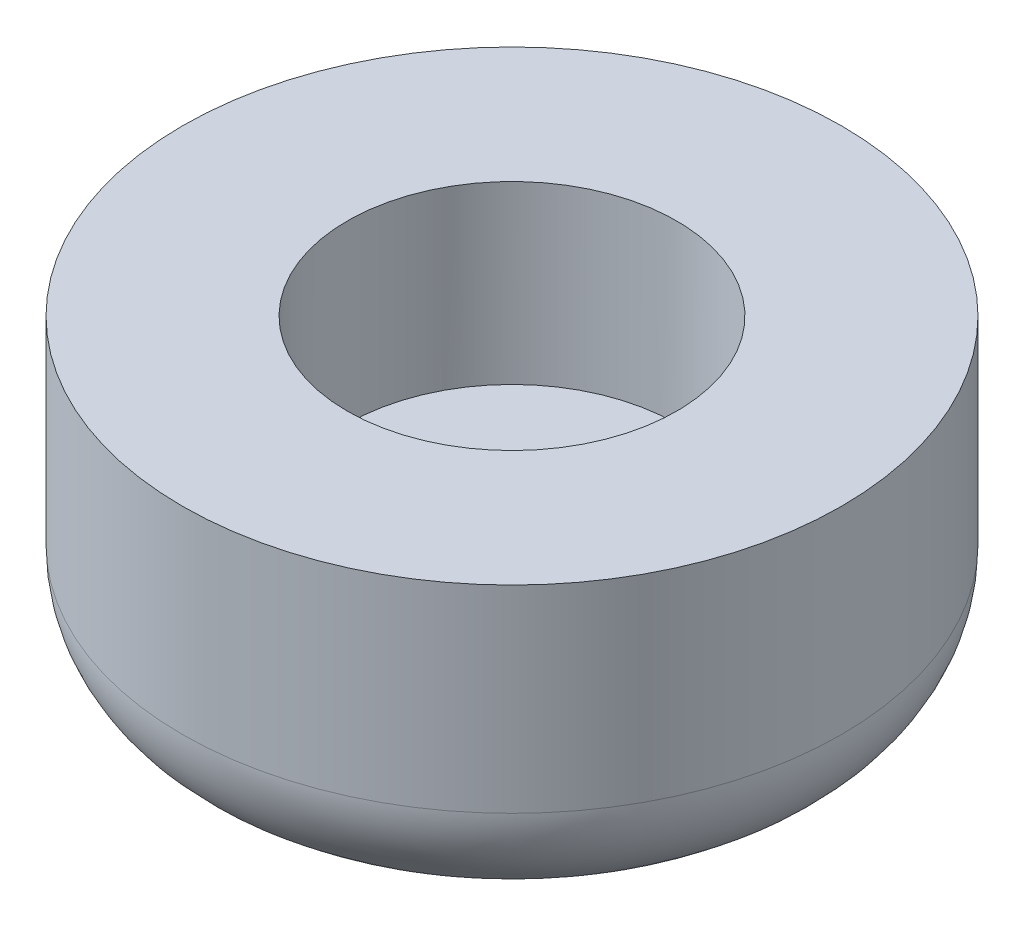
from build123d import *

# Parameters (mm, degrees)
SKETCH_1_R      = 7.5
SKETCH_1_R_2    = 3.75
EXTRUDE_1_DEPTH = 7
SKETCH_2_R      = 6
EXTRUDE_2_DEPTH = 3
FILLET_1_R      = 2.5


with BuildPart() as part:
    # Эскиз1 → Бобышка-Вытянуть1 (new body)
    with BuildSketch(Plane(origin=(0, 0, 0), x_dir=(1, 0, 0), z_dir=(0, 1, 0))):
        Circle(SKETCH_1_R)
        Circle(SKETCH_1_R_2, mode=Mode.SUBTRACT)
    extrude(amount=-EXTRUDE_1_DEPTH)

    # Эскиз2 → Бобышка-Вытянуть2 (add)
    with BuildSketch(Plane(origin=(0, -7, 0), x_dir=(-1, 0, 0), z_dir=(0, -1, 0))):
        Circle(SKETCH_2_R)
    extrude(amount=-EXTRUDE_2_DEPTH)

    # Скругление1
    fillet_1_edges = [part.edges().sort_by_distance(p)[0] for p in [
        (-7.5, -7, 0),
    ]]
    fillet(fillet_1_edges, radius=FILLET_1_R)


solid = part.part
